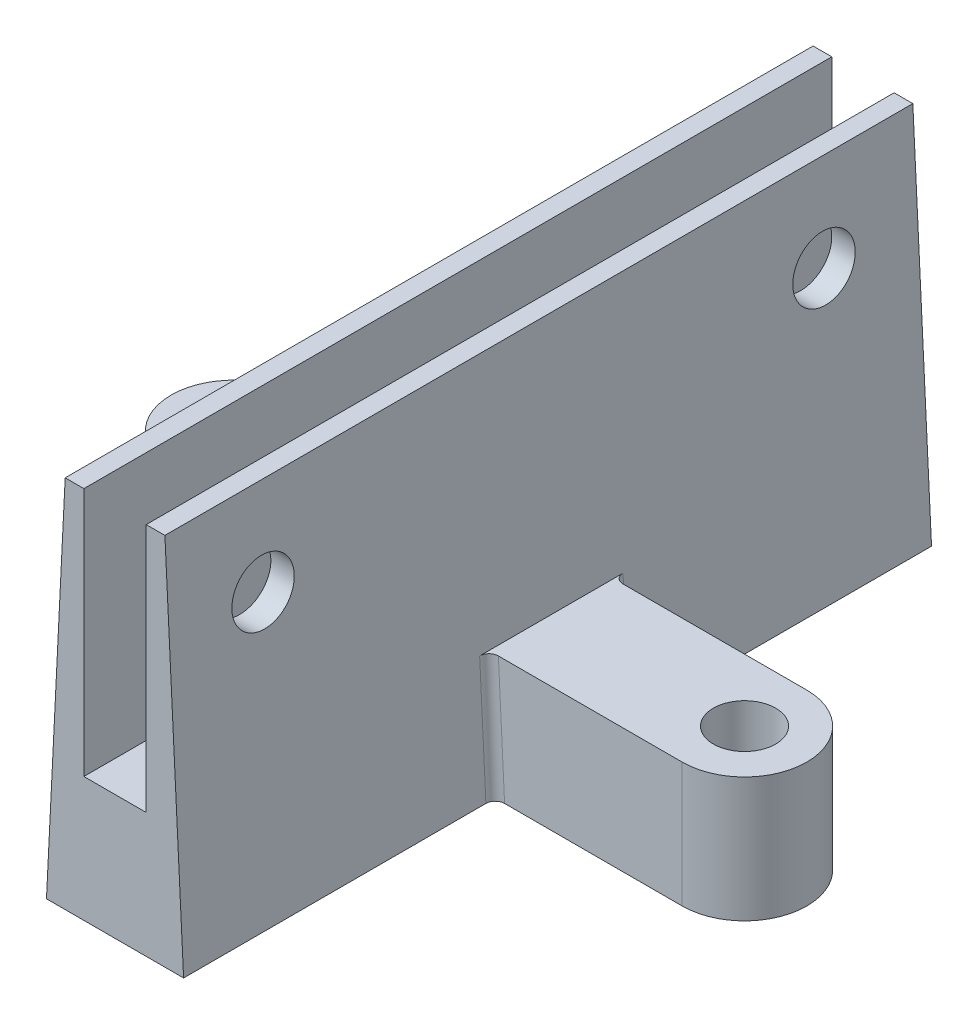
from build123d import *

# Parameters (mm, degrees)
BOSS_EXTRUDE1_DEPTH     = 120
SKETCH5_R               = 5
BOSS_EXTRUDE2_DEPTH     = 20
FILLET1_R               = 1.5
SKETCH7_R               = 5
CUT_EXTRUDE1_DEPTH      = 57
CUT_EXTRUDE1_DEPTH_BACK = 47


with BuildPart() as part:
    # Sketch2 → Boss-Extrude1 (new body)
    with BuildSketch(Plane.XY):
        Polygon((0, 0), (10, 0), (10, 40), (13, 40), (16, -20), (-6, -20), (-3, 40), (0, 40), align=None)
    extrude(amount=-BOSS_EXTRUDE1_DEPTH)

    # Sketch5 → Boss-Extrude2 (add)
    with BuildSketch(Plane.XZ.offset(20)):
        with BuildLine():
            Line((16, -50), (46, -50))
            ThreePointArc((46, -50), (56, -60), (46, -70))
            Line((46, -70), (16, -70))
            Line((16, -70), (13, -70))
            Line((13, -70), (13, -50))
            Line((13, -50), (16, -50))
        make_face()
        with Locations((46, -60)):
            Circle(SKETCH5_R, mode=Mode.SUBTRACT)
        with BuildLine():
            Line((-6, -50), (-36, -50))
            ThreePointArc((-36, -50), (-46, -60), (-36, -70))
            Line((-36, -70), (-6, -70))
            Line((-6, -70), (-3, -70))
            Line((-3, -70), (-3, -50))
            Line((-3, -50), (-6, -50))
        make_face()
        with Locations((-36, -60)):
            Circle(SKETCH5_R, mode=Mode.SUBTRACT)
    extrude(amount=-BOSS_EXTRUDE2_DEPTH)

    # Fillet1
    fillet1_edges = [part.edges().sort_by_distance(p)[0] for p in [
        (15.5, -10, -50),
        (15.5, -10, -70),
        (-5.5, -10, -50),
        (-5.5, -10, -70),
    ]]
    fillet(fillet1_edges, radius=FILLET1_R)

    # Sketch7 → Cut-Extrude1 (cut, two sides)
    with BuildSketch(Plane(origin=(0, 0, 0), x_dir=(0, 0, -1), z_dir=(1, 0, 0))) as cut_extrude1_sk:
        with Locations((15, 25)):
            Circle(SKETCH7_R)
        with Locations((105, 25)):
            Circle(SKETCH7_R)
    extrude(amount=CUT_EXTRUDE1_DEPTH, mode=Mode.SUBTRACT)
    extrude(cut_extrude1_sk.sketch, amount=-CUT_EXTRUDE1_DEPTH_BACK, mode=Mode.SUBTRACT)


solid = part.part
